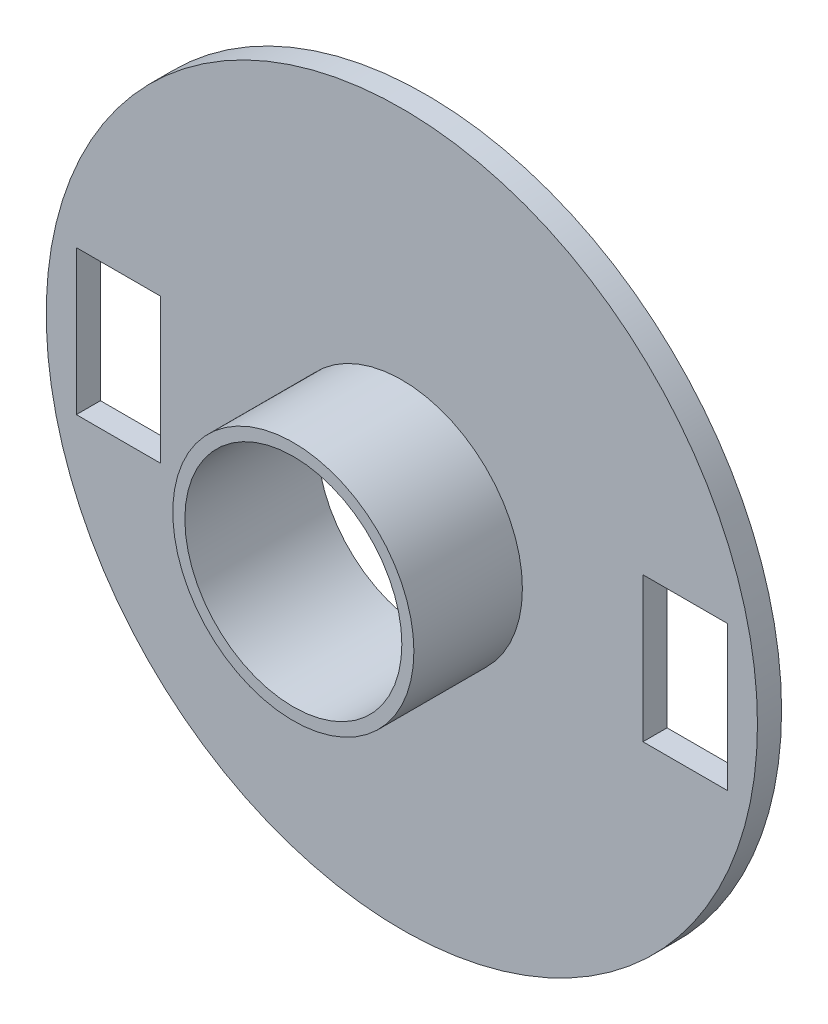
from build123d import *

# Parameters (mm, degrees)
SKETCH1_R           = 14.75
BOSS_EXTRUDE1_DEPTH = 1
SKETCH2_R           = 5
BOSS_EXTRUDE2_DEPTH = 4.5
SKETCH3_R           = 4.5
SKETCH3_W           = 3.5
SKETCH3_H           = 6
CUT_EXTRUDE1_DEPTH  = 6.5


with BuildPart() as part:
    # Sketch1 → Boss-Extrude1 (new body)
    with BuildSketch(Plane.XY):
        Circle(SKETCH1_R)
    extrude(amount=BOSS_EXTRUDE1_DEPTH)

    # Sketch2 → Boss-Extrude2 (add)
    with BuildSketch(Plane.XY.offset(1)):
        Circle(SKETCH2_R)
    extrude(amount=BOSS_EXTRUDE2_DEPTH)

    # Sketch3 → Cut-Extrude1 (cut, through all)
    with BuildSketch(Plane.XY.offset(5.5)):
        Circle(SKETCH3_R)
        with Locations((-11.75, 0)):
            Rectangle(SKETCH3_W, SKETCH3_H)
        with Locations((11.75, 0)):
            Rectangle(SKETCH3_W, SKETCH3_H)
    extrude(amount=-CUT_EXTRUDE1_DEPTH, mode=Mode.SUBTRACT)


solid = part.part
